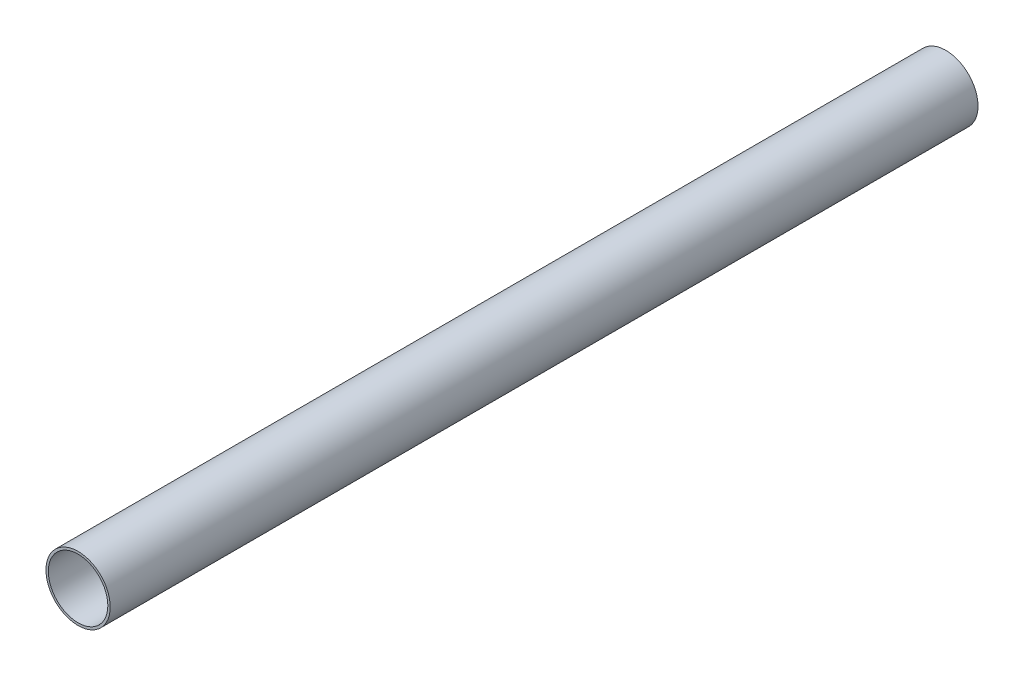
from build123d import *

# Parameters (mm, degrees)
PIPESKETCH_R    = 203.2
PIPESKETCH_R_2  = 188.1124
EXTRUSION_DEPTH = 5486.4


with BuildPart() as part:
    # PipeSketch → Extrusion (new body)
    with BuildSketch(Plane.XY):
        Circle(PIPESKETCH_R)
        Circle(PIPESKETCH_R_2, mode=Mode.SUBTRACT)
    extrude(amount=EXTRUSION_DEPTH)


solid = part.part
